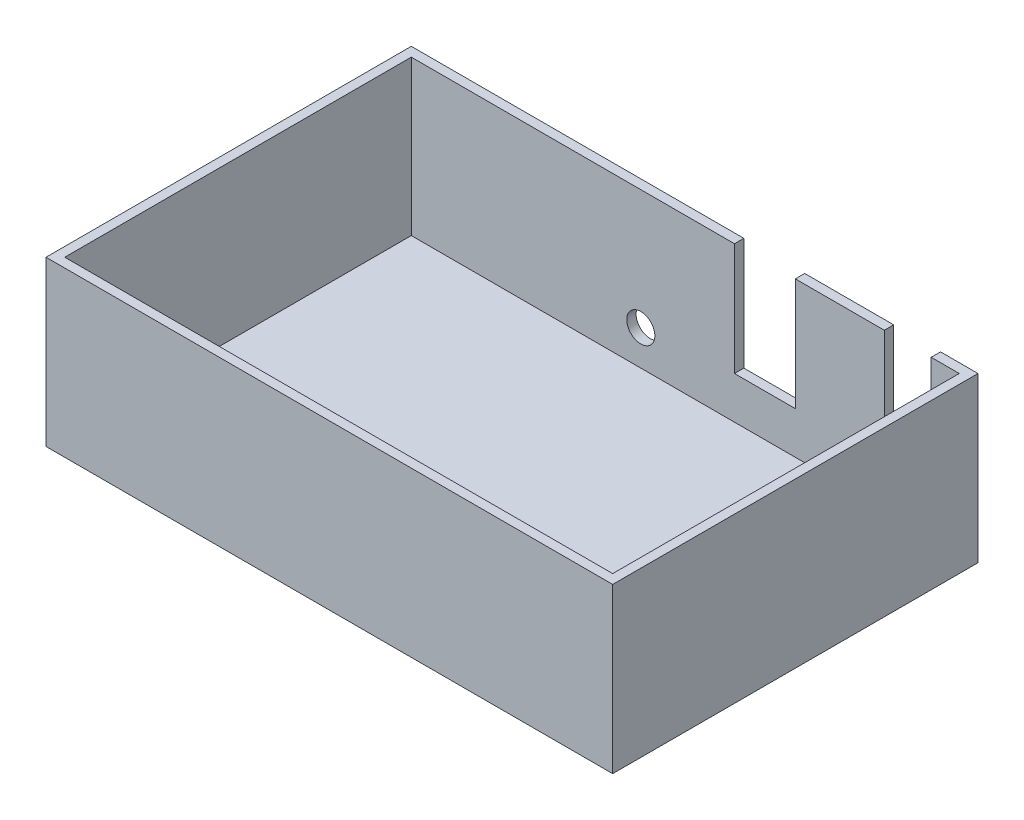
from build123d import *

# Parameters (mm, degrees)
SKETCH1_W           = 121
SKETCH1_H           = 78
BOSS_EXTRUDE3_DEPTH = 35
SKETCH4_W           = 117
SKETCH4_H           = 74
CUT_EXTRUDE1_DEPTH  = 33
SKETCH5_W           = 10
SKETCH5_H           = 23
SKETCH5_W_2         = 13
SKETCH5_H_2         = 24
CUT_EXTRUDE2_DEPTH  = 33
SKETCH6_R           = 3
CUT_EXTRUDE3_DEPTH  = 33
CUT_EXTRUDE4_DEPTH  = 1


with BuildPart() as part:
    # Sketch1 → Boss-Extrude3 (new body)
    with BuildSketch(Plane(origin=(0, 0, 0), x_dir=(1, 0, 0), z_dir=(0, 1, 0))):
        with Locations((60.5, 39)):
            Rectangle(SKETCH1_W, SKETCH1_H)
    extrude(amount=BOSS_EXTRUDE3_DEPTH)

    # Sketch4 → Cut-Extrude1 (cut)
    with BuildSketch(Plane(origin=(0, 35, 0), x_dir=(1, 0, 0), z_dir=(0, 1, 0))):
        with Locations((60.5, 39)):
            Rectangle(SKETCH4_W, SKETCH4_H)
    extrude(amount=-CUT_EXTRUDE1_DEPTH, mode=Mode.SUBTRACT)

    # Sketch5 → Cut-Extrude2 (cut)
    with BuildSketch(Plane(origin=(0, 0, -78), x_dir=(-1, 0, 0), z_dir=(0, 0, -1))):
        with Locations((-108, 23.5)):
            Rectangle(SKETCH5_W, SKETCH5_H)
        with Locations((-77.5, 23)):
            Rectangle(SKETCH5_W_2, SKETCH5_H_2)
    extrude(amount=-CUT_EXTRUDE2_DEPTH, mode=Mode.SUBTRACT)

    # Sketch6 → Cut-Extrude3 (cut)
    with BuildSketch(Plane(origin=(0, 0, -78), x_dir=(-1, 0, 0), z_dir=(0, 0, -1))):
        with Locations((-51, 9.463298595)):
            Circle(SKETCH6_R)
    extrude(amount=-CUT_EXTRUDE3_DEPTH, mode=Mode.SUBTRACT)

    # Sketch7 → Cut-Extrude4 (cut)
    with BuildSketch(Plane(origin=(0, 0, 0), x_dir=(-1, 0, 0), z_dir=(0, -1, 0))):
        with BuildLine():
            Line((-114.434159313, 75.289773702), (-114.434159313, 74.964132677))
            Line((-114.434159313, 74.964132677), (-115.514117246, 74.964132677))
            Line((-115.514117246, 74.964132677), (-115.685205988, 74.129041531))
            add(Edge.make_bspline(
                [(-115.685205988, 74.129041531), (-115.651591016, 74.138321849), (-115.586467325, 74.156300997), (-115.490346594, 74.176263375), (-115.399095095, 74.188297028), (-115.339881009, 74.189940145), (-115.311227623, 74.190735241)],
                knots=[0, 0, 0, 0, 0.000104595, 0.000202637, 0.000294305, 0.000380252, 0.000380252, 0.000380252, 0.000380252], degree=3))
            add(Edge.make_bspline(
                [(-115.311227623, 74.190735241), (-115.275773087, 74.189967856), (-115.206060613, 74.188458987), (-115.104062425, 74.173970238), (-115.006696157, 74.151164744), (-114.914165436, 74.119305413), (-114.826299079, 74.078565869), (-114.743905506, 74.027675209), (-114.66574797, 73.968227116), (-114.593228617, 73.899878427), (-114.527438709, 73.824656674), (-114.469593847, 73.743777748), (-114.42046064, 73.658027655), (-114.380944812, 73.566587103), (-114.349390452, 73.470467013), (-114.328388285, 73.368656028), (-114.314403128, 73.262113805), (-114.312840677, 73.189266088), (-114.312043929, 73.152118454)],
                knots=[0, 0, 0, 0, 0.000106308, 0.000209029, 0.000308378, 0.000405929, 0.000502102, 0.000598312, 0.00069588, 0.000796219, 0.000896736, 0.000995218, 0.001094066, 0.001192613, 0.001293582, 0.001396995, 0.001504047, 0.001615439, 0.001615439, 0.001615439, 0.001615439], degree=3))
            add(Edge.make_bspline(
                [(-114.312043929, 73.152118454), (-114.312647247, 73.126244726), (-114.31384573, 73.07484693), (-114.319940449, 72.998516119), (-114.331674991, 72.923801263), (-114.347429998, 72.850692451), (-114.367879192, 72.779328092), (-114.392634262, 72.70950392), (-114.42292923, 72.641654527), (-114.45615912, 72.575137918), (-114.493575568, 72.511457844), (-114.535103214, 72.451904835), (-114.578977624, 72.395585522), (-114.626186595, 72.343103922), (-114.677168926, 72.294804898), (-114.731307182, 72.250401814), (-114.788169363, 72.20914375), (-114.84863519, 72.172705459), (-114.911357299, 72.139174777), (-114.977241468, 72.111666997), (-115.04478796, 72.087073875), (-115.114968955, 72.067470947), (-115.187625485, 72.052110701), (-115.262877317, 72.041678013), (-115.340329782, 72.034079388), (-115.392830686, 72.033603721), (-115.419350619, 72.033363446)],
                knots=[0, 0, 0, 0, 7.7636e-05, 0.000154223, 0.000229512, 0.000304362, 0.000378447, 0.000452077, 0.000526407, 0.000601214, 0.00067506, 0.000747747, 0.00081887, 0.000889121, 0.000959302, 0.001029336, 0.001099058, 0.00116985, 0.001240974, 0.00131221, 0.00138383, 0.001456517, 0.001530612, 0.001606437, 0.001684346, 0.001763871, 0.001763871, 0.001763871, 0.001763871], degree=3))
            add(Edge.make_bspline(
                [(-115.419350619, 72.033363446), (-115.450986483, 72.033990135), (-115.513226308, 72.035223071), (-115.604412823, 72.048121268), (-115.692146786, 72.066594249), (-115.77572195, 72.094385723), (-115.85588731, 72.129208483), (-115.931563633, 72.173219581), (-116.004684587, 72.223093483), (-116.072277649, 72.281949231), (-116.135012123, 72.346279886), (-116.19117017, 72.41609146), (-116.241184201, 72.49023174), (-116.2842533, 72.56906078), (-116.320990791, 72.652371447), (-116.34985153, 72.740475884), (-116.373145466, 72.832913744), (-116.38300014, 72.896553), (-116.388005467, 72.928876267)],
                knots=[0, 0, 0, 0, 9.4843e-05, 0.000186593, 0.000275792, 0.000363484, 0.000450342, 0.000537514, 0.000625728, 0.000715478, 0.000805885, 0.000894984, 0.00098389, 0.001073836, 0.001164117, 0.001256635, 0.001351658, 0.001449737, 0.001449737, 0.001449737, 0.001449737], degree=3))
            Line((-116.388005467, 72.928876267), (-116.10306957, 72.928876267))
            add(Edge.make_bspline(
                [(-116.10306957, 72.928876267), (-116.096058664, 72.898599056), (-116.082583314, 72.840404576), (-116.053005242, 72.758642574), (-116.016841198, 72.685781564), (-115.973838682, 72.620857728), (-115.922539726, 72.564243852), (-115.864002315, 72.513791231), (-115.798372595, 72.468275221), (-115.725444451, 72.430335996), (-115.648506872, 72.397979342), (-115.567982331, 72.376433161), (-115.486063388, 72.361283065), (-115.430656581, 72.35976654), (-115.402814161, 72.359004472)],
                knots=[0, 0, 0, 0, 9.3172e-05, 0.000179081, 0.000260145, 0.000336703, 0.000411917, 0.000488562, 0.000568128, 0.000650923, 0.00073478, 0.000817953, 0.000900557, 0.000983994, 0.000983994, 0.000983994, 0.000983994], degree=3))
            add(Edge.make_bspline(
                [(-115.402814161, 72.359004472), (-115.375637572, 72.359749034), (-115.322126646, 72.361215085), (-115.243376317, 72.372499046), (-115.167346067, 72.3898777), (-115.094786107, 72.415885354), (-115.024426711, 72.447494491), (-114.958047648, 72.488057453), (-114.893728609, 72.534739041), (-114.833468802, 72.588221127), (-114.77827873, 72.647157921), (-114.729514249, 72.710183842), (-114.688895192, 72.77741841), (-114.654664965, 72.847697628), (-114.628672329, 72.921791747), (-114.610129439, 72.999353528), (-114.59924095, 73.080574545), (-114.597743094, 73.135973134), (-114.596979826, 73.164202789)],
                knots=[0, 0, 0, 0, 8.15e-05, 0.000160473, 0.000238226, 0.000315066, 0.000391338, 0.000469218, 0.000547964, 0.000629516, 0.000710512, 0.000789892, 0.000868102, 0.000945761, 0.001024012, 0.00110315, 0.001184644, 0.001269321, 0.001269321, 0.001269321, 0.001269321], degree=3))
            add(Edge.make_bspline(
                [(-114.596979826, 73.164202789), (-114.597577161, 73.189671506), (-114.598746359, 73.239522897), (-114.608299091, 73.312456463), (-114.624915201, 73.38146558), (-114.647978293, 73.446883492), (-114.677260417, 73.508771901), (-114.713043858, 73.567194677), (-114.756000155, 73.621381797), (-114.805069225, 73.671358613), (-114.858824733, 73.717482178), (-114.918191557, 73.756801457), (-114.981927348, 73.789879439), (-115.049264199, 73.818425409), (-115.121803785, 73.838927514), (-115.198109588, 73.85431981), (-115.279005601, 73.863223746), (-115.334314725, 73.864459174), (-115.36274505, 73.865094215)],
                knots=[0, 0, 0, 0, 7.6388e-05, 0.000149519, 0.000220172, 0.000288967, 0.000357247, 0.000425206, 0.000494043, 0.000564207, 0.000635056, 0.000706145, 0.000777268, 0.000850264, 0.000925136, 0.001002969, 0.001083601, 0.001168886, 0.001168886, 0.001168886, 0.001168886], degree=3))
            add(Edge.make_bspline(
                [(-115.36274505, 73.865094215), (-115.387354864, 73.864567536), (-115.438167887, 73.863480077), (-115.516112165, 73.855473184), (-115.598019657, 73.84255611), (-115.683576378, 73.824788585), (-115.773039267, 73.801537537), (-115.866219531, 73.773675097), (-115.963313087, 73.740362998), (-116.028734165, 73.715205919), (-116.062364441, 73.702273702)],
                knots=[0, 0, 0, 0, 7.3822e-05, 0.000152423, 0.000234822, 0.000322511, 0.00041445, 0.000512043, 0.000614219, 0.000722306, 0.000722306, 0.000722306, 0.000722306], degree=3))
            Line((-116.062364441, 73.702273702), (-115.736723416, 75.289773702))
            Line((-115.736723416, 75.289773702), (-114.434159313, 75.289773702))
        make_face()
        Polygon((-112.253254866, 75.371183959), (-112.195377262, 75.371183959), (-112.195377262, 73.173107036), (-111.829031108, 73.173107036), (-111.829031108, 72.84746601), (-112.195377262, 72.84746601), (-112.195377262, 72.114773702), (-112.480313159, 72.114773702), (-112.480313159, 72.84746601), (-113.986402903, 72.84746601), align=None)
        Polygon((-112.480313159, 73.173107036), (-112.480313159, 74.551993254), (-113.42670739, 73.173107036), align=None, mode=Mode.SUBTRACT)
    extrude(amount=-CUT_EXTRUDE4_DEPTH, mode=Mode.SUBTRACT)


solid = part.part
